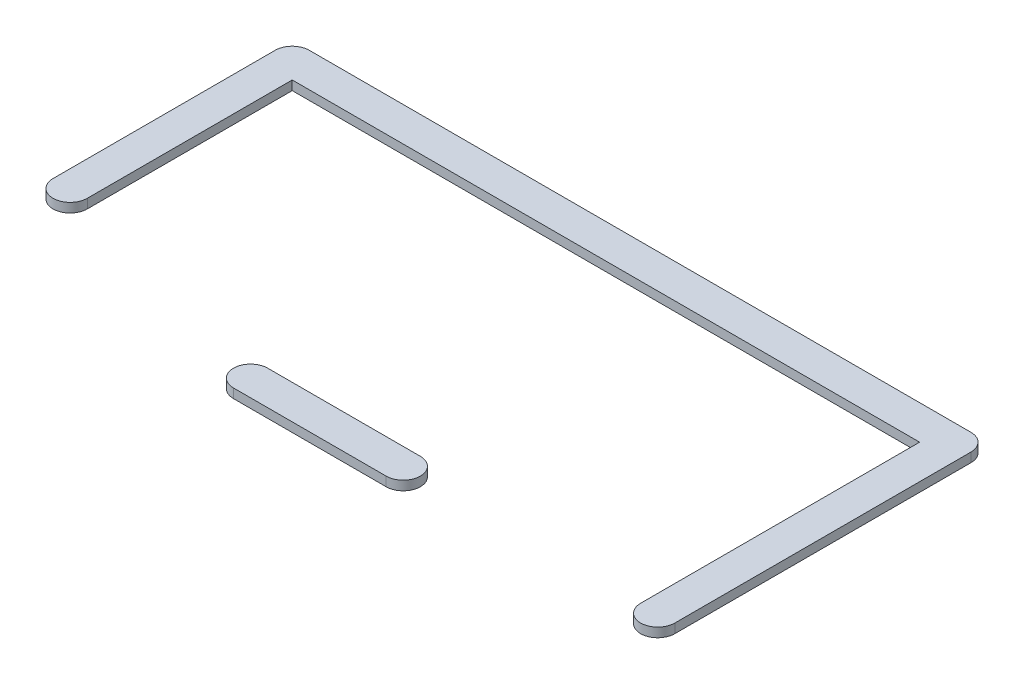
from build123d import *

# Parameters (mm, degrees)
EXTRUDE_3_DEPTH   = 20
EXTRUDE_3_2_DEPTH = 20


with BuildPart() as part:
    # 草图5 → 凸台-拉伸3 (new body)
    with BuildSketch(Plane(origin=(0, 0, 0), x_dir=(1, 0, 0), z_dir=(0, 1, 0))):
        with BuildLine():
            Line((37, -480), (37, -37))
            Line((37, -37), (1393, -37))
            Line((1393, -37), (1393, -640))
            ThreePointArc((1393, -640), (1430, -677), (1467, -640))
            Line((1467, -640), (1467, 0))
            ThreePointArc((1467, 0), (1456.162950904, 26.162950904), (1430, 37))
            Line((1430, 37), (0, 37))
            ThreePointArc((0, 37), (-26.162950904, 26.162950904), (-37, 0))
            Line((-37, 0), (-37, -480))
            ThreePointArc((-37, -480), (0, -517), (37, -480))
        make_face()
    extrude(amount=-EXTRUDE_3_DEPTH)


with BuildPart() as body_2:
    # 草图5 → Extrude 3 2 (new body)
    with BuildSketch(Plane(origin=(0, 0, 0), x_dir=(1, 0, 0), z_dir=(0, 1, 0))):
        with BuildLine():
            Line((550, -677), (880, -677))
            ThreePointArc((880, -677), (917, -640), (880, -603))
            Line((880, -603), (550, -603))
            ThreePointArc((550, -603), (513, -640), (550, -677))
        make_face()
    extrude(amount=-EXTRUDE_3_2_DEPTH)


solid = Compound([part.part, body_2.part])
